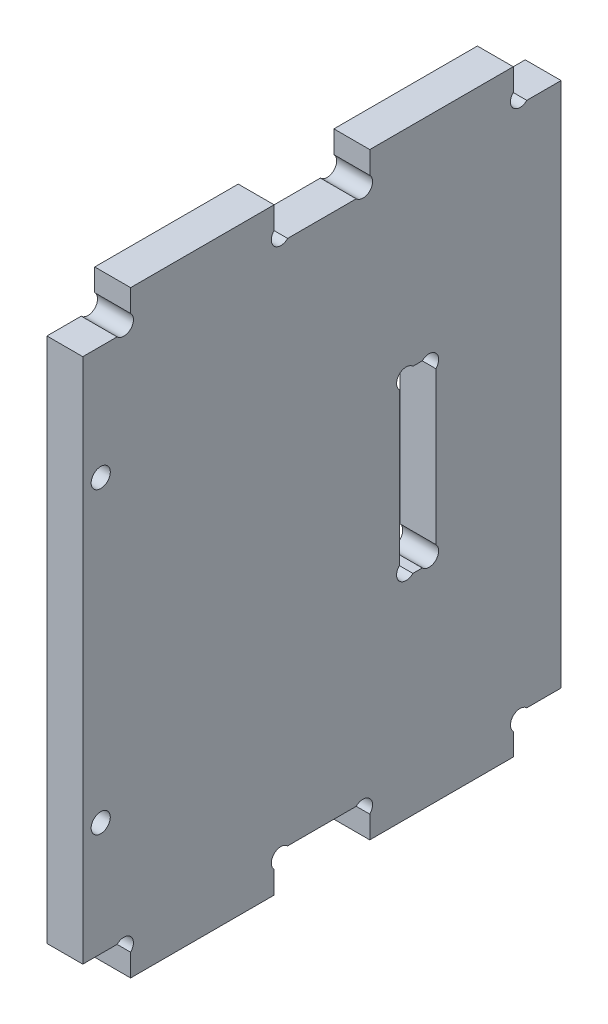
from build123d import *

# Parameters (mm, degrees)
ESQUISSE1_R      = 1.6
EXTRUSION1_DEPTH = 6


with BuildPart() as part:
    # Esquisse1 → Extrusion1 (new body)
    with BuildSketch(Plane(origin=(0, 0, 0), x_dir=(0, 0, -1), z_dir=(1, 0, 0))):
        with BuildLine():
            Line((0, 94), (5.7372583, 94))
            ThreePointArc((5.7372583, 94), (8, 94), (8, 96.2627417))
            Line((8, 96.2627417), (8, 100))
            Line((8, 100), (32, 100))
            Line((32, 100), (32, 96.2627417))
            ThreePointArc((32, 96.2627417), (32, 94), (34.2627417, 94))
            Line((34.2627417, 94), (45.7372583, 94))
            ThreePointArc((45.7372583, 94), (48, 94), (48, 96.2627417))
            Line((48, 96.2627417), (48, 100))
            Line((48, 100), (72, 100))
            Line((72, 100), (72, 96.2627417))
            ThreePointArc((72, 96.2627417), (72, 94), (74.2627417, 94))
            Line((74.2627417, 94), (80, 94))
            Line((80, 94), (80, 6))
            Line((80, 6), (74.2627417, 6))
            ThreePointArc((74.2627417, 6), (72, 6), (72, 3.7372583))
            Line((72, 3.7372583), (72, 0))
            Line((72, 0), (48, 0))
            Line((48, 0), (48, 3.7372583))
            ThreePointArc((48, 3.7372583), (48, 6), (45.7372583, 6))
            Line((45.7372583, 6), (34.2627417, 6))
            ThreePointArc((34.2627417, 6), (32, 6), (32, 3.7372583))
            Line((32, 3.7372583), (32, 0))
            Line((32, 0), (8, 0))
            Line((8, 0), (8, 3.7372583))
            ThreePointArc((8, 3.7372583), (8, 6), (5.7372583, 6))
            Line((5.7372583, 6), (0, 6))
            Line((0, 6), (0, 94))
        make_face()
        with Locations((3, 25)):
            Circle(ESQUISSE1_R, mode=Mode.SUBTRACT)
        with Locations(Location((3, 75, 0), (0, 0, 180))):  # turned: the seam where the file's is
            Circle(ESQUISSE1_R, mode=Mode.SUBTRACT)
        with BuildLine():
            Line((55.2127417, 65), (56.7872583, 65))
            ThreePointArc((56.7872583, 65), (59.05, 65), (59.05, 62.7372583))
            Line((59.05, 62.7372583), (59.05, 37.2627417))
            ThreePointArc((59.05, 37.2627417), (59.05, 35), (56.7872583, 35))
            Line((56.7872583, 35), (55.2127417, 35))
            ThreePointArc((55.2127417, 35), (52.95, 35), (52.95, 37.2627417))
            Line((52.95, 37.2627417), (52.95, 62.7372583))
            ThreePointArc((52.95, 62.7372583), (52.95, 65), (55.2127417, 65))
        make_face(mode=Mode.SUBTRACT)
    extrude(amount=EXTRUSION1_DEPTH)


solid = part.part
